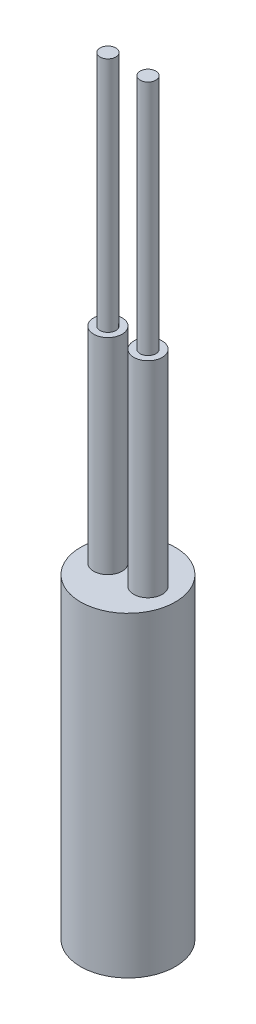
from build123d import *

# Parameters (mm, degrees)
SKETCH1_R           = 3
BOSS_EXTRUDE1_DEPTH = 20
SKETCH2_R           = 0.9
BOSS_EXTRUDE2_DEPTH = 13
SKETCH3_R           = 0.5
BOSS_EXTRUDE3_DEPTH = 15


with BuildPart() as part:
    # Sketch1 → Boss-Extrude1 (new body)
    with BuildSketch(Plane(origin=(0, 0, 0), x_dir=(1, 0, 0), z_dir=(0, 1, 0))):
        Circle(SKETCH1_R)
    extrude(amount=BOSS_EXTRUDE1_DEPTH)

    # Sketch2 → Boss-Extrude2 (add)
    with BuildSketch(Plane(origin=(0, 20, 0), x_dir=(1, 0, 0), z_dir=(0, 1, 0))):
        with Locations((1.27, 0)):
            Circle(SKETCH2_R)
        with Locations((-1.27, 0)):
            Circle(SKETCH2_R)
    extrude(amount=BOSS_EXTRUDE2_DEPTH)

    # Sketch3 → Boss-Extrude3 (add)
    with BuildSketch(Plane(origin=(0, 33, 0), x_dir=(1, 0, 0), z_dir=(0, 1, 0))):
        with Locations((1.27, 0)):
            Circle(SKETCH3_R)
        with Locations((-1.27, 0)):
            Circle(SKETCH3_R)
    extrude(amount=BOSS_EXTRUDE3_DEPTH)


solid = part.part
